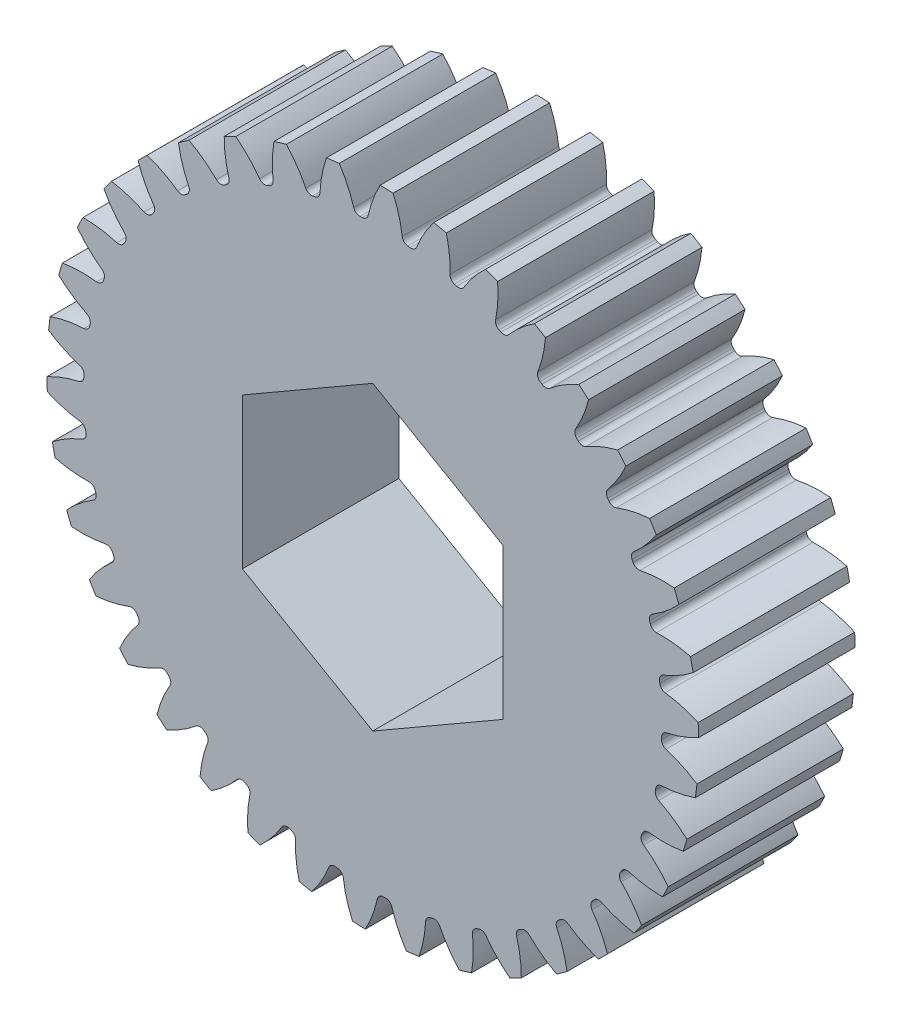
from build123d import *

# Parameters (mm, degrees)
SKETCH3_R          = 15.875
GEARBODY_DEPTH     = 7.62
TOOTHCUT_DEPTH     = 8.62
CIRPATTERN1_COUNT  = 38
BOREDIA_R          = 3.175
BORE_DEPTH         = 12700
CUT_EXTRUDE1_DEPTH = 8.62


with BuildPart() as part:
    # Sketch3 → gearBody (new body)
    with BuildSketch(Plane.XY):
        Circle(SKETCH3_R)
    extrude(amount=GEARBODY_DEPTH)

    # Sketch2 → toothCut (cut, through all)
    with BuildSketch(Plane.XY):
        with BuildLine():
            ThreePointArc((14.062628491, -0.656624806), (14.065191003, -0.599231392), (14.067519277, -0.541827999))
            ThreePointArc((14.067519277, -0.541827999), (14.138575942, -0.358032756), (14.307481615, -0.256540814))
            ThreePointArc((14.307481615, -0.256540814), (16.331366399, 0.601636221), (17.89135535, 2.150510623))
            ThreePointArc((17.89135535, 2.150510623), (18.0038039, -0.767031494), (17.64361613, -3.664437482))
            ThreePointArc((17.64361613, -3.664437482), (16.22101689, -1.988493317), (14.277456674, -0.961287822))
            ThreePointArc((14.277456674, -0.961287822), (14.117795276, -0.845797654), (14.062628491, -0.656624806))
        make_face()
    toothcut = extrude(amount=TOOTHCUT_DEPTH, mode=Mode.SUBTRACT)

    # CirPattern1: toothCut ×38 about axis
    cirpattern1_axis = Axis((0, 0, 0), (0, 0, 1))
    for i in range(1, CIRPATTERN1_COUNT):
        add(toothcut.rotate(cirpattern1_axis, i * 360 / CIRPATTERN1_COUNT), mode=Mode.SUBTRACT)

    # boreDia → bore (cut, symmetric)
    with BuildSketch(Plane.XY):
        Circle(BOREDIA_R)
    extrude(amount=BORE_DEPTH, both=True, mode=Mode.SUBTRACT)

    # Sketch4 → Cut-Extrude1 (cut, through all)
    with BuildSketch(Plane(origin=(0, 0, 0), x_dir=(-1, 0, 0), z_dir=(0, 0, -1))):
        Polygon((0, 7.332348419), (-6.35, 3.666174209), (-6.35, -3.666174209), (0, -7.332348419), (6.35, -3.666174209), (6.35, 3.666174209), align=None)
    extrude(amount=-CUT_EXTRUDE1_DEPTH, mode=Mode.SUBTRACT)


solid = part.part
